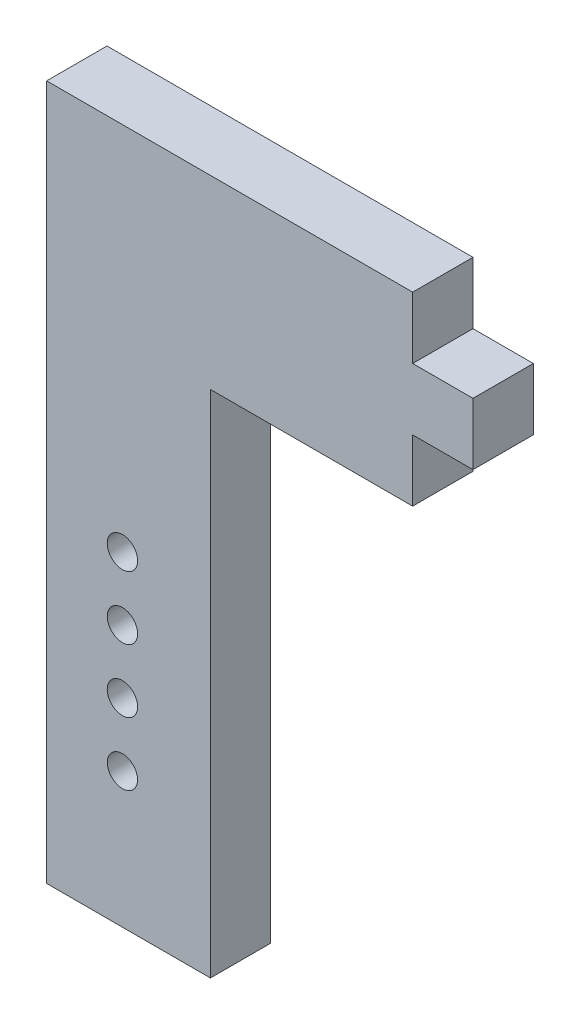
from build123d import *

# Parameters (mm, degrees)
SKETCH1_W           = 13.462
SKETCH1_H           = 57.15
BOSS_EXTRUDE1_DEPTH = 4.9609375
SKETCH2_W           = 4.9609375
SKETCH2_H           = 15.24
BOSS_EXTRUDE2_DEPTH = 21.59
SKETCH5_R           = 1.2446
SKETCH5_R_2         = 1.25
SKETCH5_R_3         = 1.24968
CUT_EXTRUDE2_DEPTH  = 5.9609375
SKETCH6_OUTSIDE_W   = 20.407
SKETCH6_OUTSIDE_H   = 72.596
SKETCH6_OUTSIDE_W_2 = 4.9609375
SKETCH6_OUTSIDE_H_2 = 5.08
CUT_EXTRUDE3_DEPTH  = 4.9609375


with BuildPart() as part:
    # Sketch1 → Boss-Extrude1 (new body)
    with BuildSketch(Plane.XY):
        Rectangle(SKETCH1_W, SKETCH1_H)
    extrude(amount=BOSS_EXTRUDE1_DEPTH)

    # Sketch2 → Boss-Extrude2 (add)
    with BuildSketch(Plane(origin=(6.731, 0, 0), x_dir=(0, 0, -1), z_dir=(1, 0, 0))):
        with Locations((-2.48046875, 20.955)):
            Rectangle(SKETCH2_W, SKETCH2_H)
    extrude(amount=BOSS_EXTRUDE2_DEPTH)

    # Sketch5 → Cut-Extrude2 (cut, through all)
    with BuildSketch(Plane(origin=(0, 0, 0), x_dir=(-1, 0, 0), z_dir=(0, 0, -1))):
        with Locations((0.502153829, -17.4625)):
            Circle(SKETCH5_R)
        with Locations((0.502153829, -12.2625)):
            Circle(SKETCH5_R_2)
        with Locations((0.502153829, -7.0625)):
            Circle(SKETCH5_R_3)
        with Locations((0.502153829, -1.8625)):
            Circle(SKETCH5_R_3)
    extrude(amount=-CUT_EXTRUDE2_DEPTH, mode=Mode.SUBTRACT)

    # Sketch6 outside → Cut-Extrude3 (cut)
    with BuildSketch(Plane(origin=(28.321, 0, 0), x_dir=(0, 0, -1), z_dir=(1, 0, 0))):
        with Locations((-2.4805, 0)):
            Rectangle(SKETCH6_OUTSIDE_W, SKETCH6_OUTSIDE_H)
        with Locations((-2.48046875, 20.955)):
            Rectangle(SKETCH6_OUTSIDE_W_2, SKETCH6_OUTSIDE_H_2, mode=Mode.SUBTRACT)
    extrude(amount=-CUT_EXTRUDE3_DEPTH, mode=Mode.SUBTRACT)


solid = part.part
